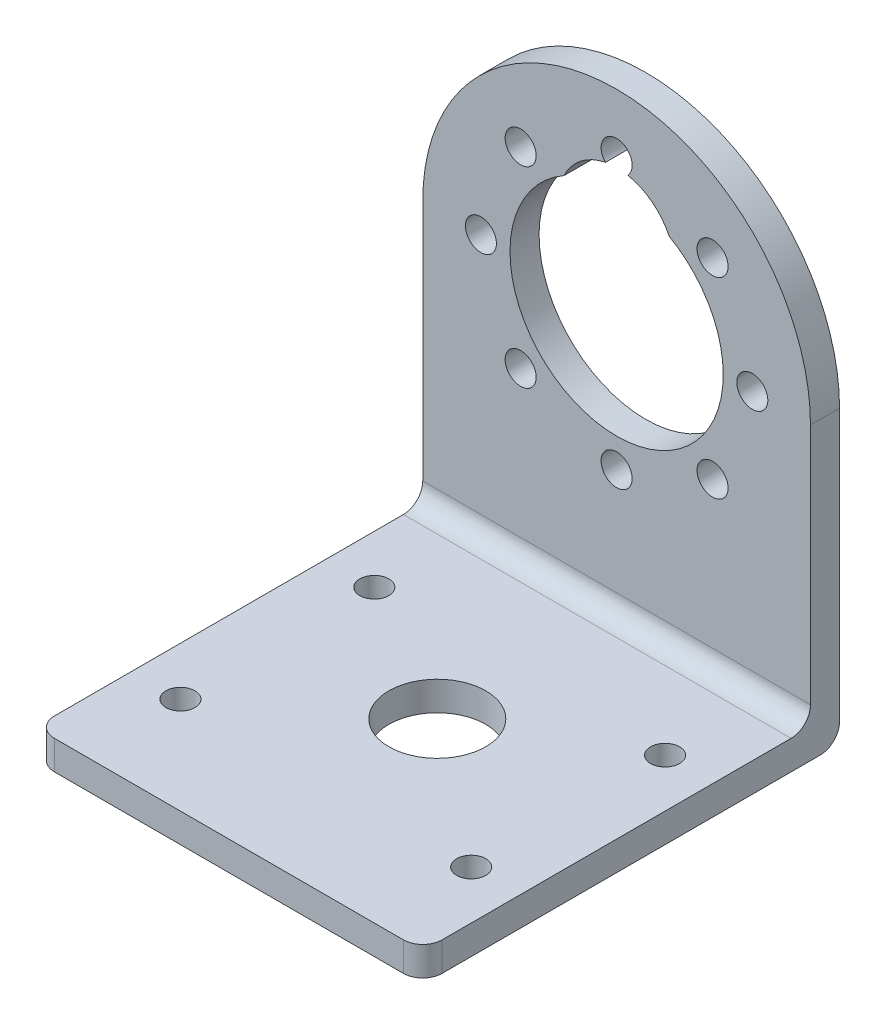
from build123d import *

# Parameters (mm, degrees)
SKETCH1_W           = 40
SKETCH1_H           = 43
SKETCH1_R           = 1.5
SKETCH1_R_2         = 5
BOSS_EXTRUDE1_DEPTH = 3
SKETCH3_R           = 1.6
BOSS_EXTRUDE2_DEPTH = 3
FILLET1_R           = 2


with BuildPart() as part:
    # Sketch1 → Boss-Extrude1 (new body)
    with BuildSketch(Plane(origin=(0, 0, 0), x_dir=(1, 0, 0), z_dir=(0, 1, 0))):
        Rectangle(SKETCH1_W, SKETCH1_H)
        with Locations((-15, -11.5)):
            Circle(SKETCH1_R, mode=Mode.SUBTRACT)
        with Locations((15, -11.5)):
            Circle(SKETCH1_R, mode=Mode.SUBTRACT)
        with Locations((-15, 8.5)):
            Circle(SKETCH1_R, mode=Mode.SUBTRACT)
        with Locations((15, 8.5)):
            Circle(SKETCH1_R, mode=Mode.SUBTRACT)
        Circle(SKETCH1_R_2, mode=Mode.SUBTRACT)
    extrude(amount=BOSS_EXTRUDE1_DEPTH)

    # Sketch3 → Boss-Extrude2 (add)
    with BuildSketch(Plane(origin=(0, 0, -21.5), x_dir=(-1, 0, 0), z_dir=(0, 0, -1))):
        with BuildLine():
            Line((-20, 3), (20, 3))
            Line((20, 3), (20, 30))
            ThreePointArc((20, 30), (0, 50), (-20, 30))
            Line((-20, 30), (-20, 3))
        make_face()
        with Locations((0, 16)):
            Circle(SKETCH3_R, mode=Mode.SUBTRACT)
        with Locations((-9.899494937, 20.100505063)):
            Circle(SKETCH3_R, mode=Mode.SUBTRACT)
        with Locations((-14, 30)):
            Circle(SKETCH3_R, mode=Mode.SUBTRACT)
        with Locations((-9.899494937, 39.899494937)):
            Circle(SKETCH3_R, mode=Mode.SUBTRACT)
        with Locations((9.899494937, 39.899494937)):
            Circle(SKETCH3_R, mode=Mode.SUBTRACT)
        with Locations((14, 30)):
            Circle(SKETCH3_R, mode=Mode.SUBTRACT)
        with Locations((9.899494937, 20.100505063)):
            Circle(SKETCH3_R, mode=Mode.SUBTRACT)
        with BuildLine():
            ThreePointArc((-5.421047417, 39.571428571), (0, 19), (5.421047417, 39.571428571))
            ThreePointArc((5.421047417, 39.571428571), (3.680856516, 41.738279783), (1.15096765, 42.888571429))
            ThreePointArc((1.15096765, 42.888571429), (0, 45.6), (-1.15096765, 42.888571429))
            ThreePointArc((-1.15096765, 42.888571429), (-3.680856516, 41.738279783), (-5.421047417, 39.571428571))
        make_face(mode=Mode.SUBTRACT)
    extrude(amount=-BOSS_EXTRUDE2_DEPTH)

    # Fillet1
    fillet1_edges = [part.edges().sort_by_distance(p)[0] for p in [
        (0, 3, -18.5),
        (0, 0, -21.5),
        (20, 1.5, 21.5),
        (-20, 1.5, 21.5),
    ]]
    fillet(fillet1_edges, radius=FILLET1_R)


solid = part.part
